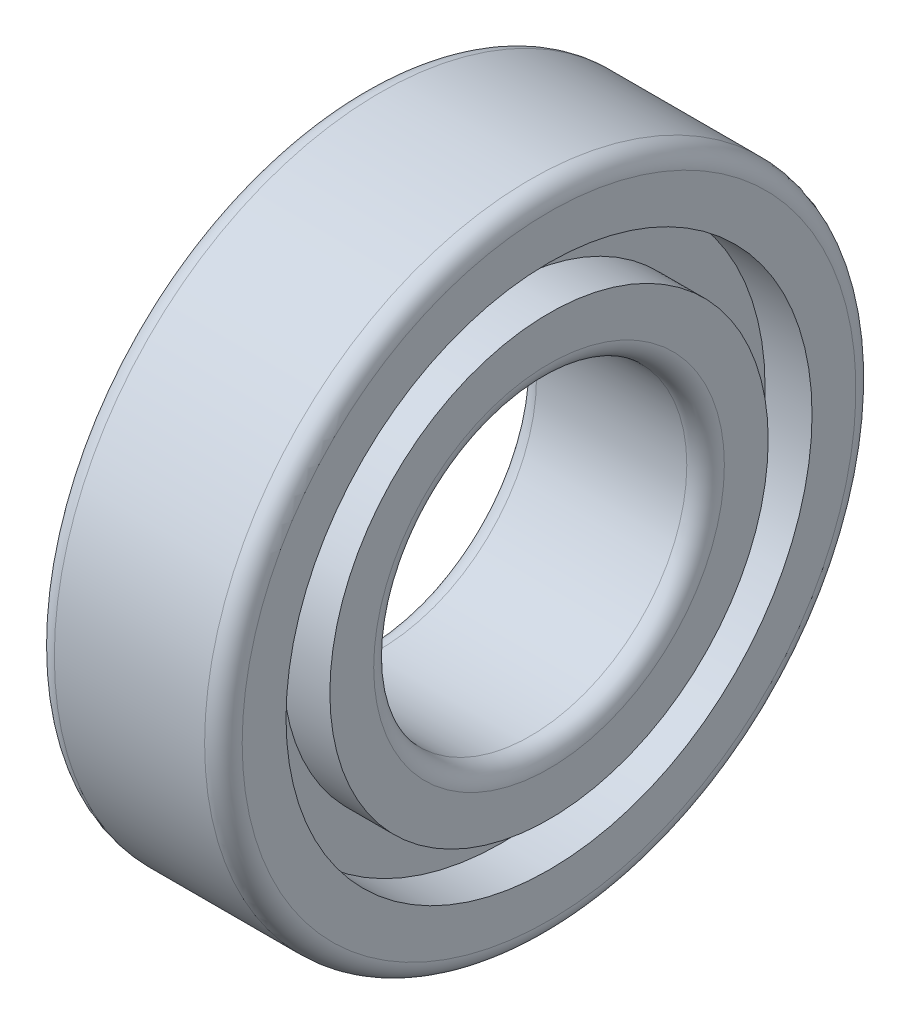
from build123d import *


with BuildPart() as part:
    # Эскиз1 → Повернуть1 (revolve)
    with BuildSketch(Plane.XY):
        with BuildLine():
            Line((6, 12.5), (-6, 12.5))
            ThreePointArc((-6, 12.5), (-7.060660172, 12.939339828), (-7.5, 14))
            Line((-7.5, 14), (-7.5, 17.5))
            Line((-7.5, 17.5), (-3.75, 17.5))
            Line((-3.75, 17.5), (-3.75, 21))
            Line((-3.75, 21), (-7.5, 21))
            Line((-7.5, 21), (-7.5, 24.5))
            ThreePointArc((-7.5, 24.5), (-7.060660172, 25.560660172), (-6, 26))
            Line((-6, 26), (6, 26))
            ThreePointArc((6, 26), (7.060660172, 25.560660172), (7.5, 24.5))
            Line((7.5, 24.5), (7.5, 21))
            Line((7.5, 21), (3.75, 21))
            Line((3.75, 21), (3.75, 17.5))
            Line((3.75, 17.5), (7.5, 17.5))
            Line((7.5, 17.5), (7.5, 14))
            ThreePointArc((7.5, 14), (7.060660172, 12.939339828), (6, 12.5))
        make_face()
    revolve(axis=Axis((-873.991742101, 0, 0), (1, 0, 0)))


solid = part.part
